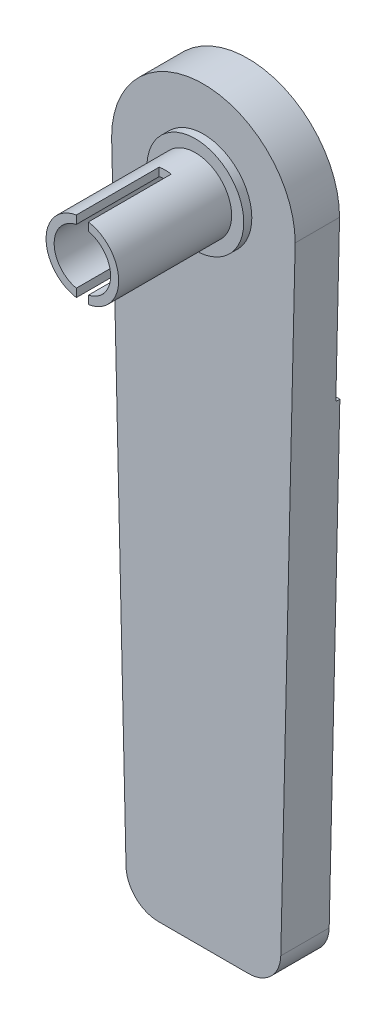
from build123d import *

# Parameters (mm, degrees)
EXTRUDE_1_DEPTH     = 6
FILLET_1_R          = 4
SKETCH_2_R          = 4.5
EXTRUDE_2_DEPTH     = 15
SKETCH_4_R          = 6
EXTRUDE_3_DEPTH     = 1
SKETCH_5_R          = 3.5
CUT_EXTRUDE_1_DEPTH = 15
SKETCH_6_W          = 1.5
SKETCH_6_H          = 10.26625424
CUT_EXTRUDE_2_DEPTH = 16.875
CUT_EXTRUDE_3_DEPTH = 0.5


with BuildPart() as part:
    # 草圖1 → 填料-伸長1 (new body)
    with BuildSketch(Plane.XY):
        with BuildLine():
            Line((-11.362913376, -0.524237167), (-9.5, -81.325))
            Line((-9.5, -81.325), (9.5, -81.325))
            Line((9.5, -81.325), (11.362913376, -0.524237167))
            Line((11.362913376, -0.524237167), (11.375, 0))
            ThreePointArc((11.375, 0), (0, 11.375), (-11.375, 0))
            Line((-11.375, 0), (-11.362913376, -0.524237167))
        make_face()
    extrude(amount=EXTRUDE_1_DEPTH)

    # 圓角1
    fillet_1_edges = [part.edges().sort_by_distance(p)[0] for p in [
        (9.5, -81.325, 3),
        (-9.5, -81.325, 3),
    ]]
    fillet(fillet_1_edges, radius=FILLET_1_R)

    # 草圖2 → 填料-伸長2 (add)
    with BuildSketch(Plane.XY.offset(6)):
        Circle(SKETCH_2_R)
    extrude(amount=EXTRUDE_2_DEPTH)

    # 草圖4 → 填料-伸長3 (add)
    with BuildSketch(Plane.XY.offset(6)):
        Circle(SKETCH_4_R)
    extrude(amount=EXTRUDE_3_DEPTH)

    # 草圖5 → 除料-伸長1 (cut)
    with BuildSketch(Plane.XY.offset(21)):
        Circle(SKETCH_5_R)
    extrude(amount=-CUT_EXTRUDE_1_DEPTH, mode=Mode.SUBTRACT)

    # 草圖6 → 除料-伸長2 (cut, through all)
    with BuildSketch(Plane(origin=(0, -4.5, 0), x_dir=(-1, 0, 0), z_dir=(0, -1, 0))):
        with Locations((0, -15.86687288)):
            Rectangle(SKETCH_6_W, SKETCH_6_H)
    extrude(amount=-CUT_EXTRUDE_2_DEPTH, mode=Mode.SUBTRACT)

    # 草圖7 → 除料-伸長3 (cut)
    with BuildSketch(Plane(origin=(0, 0, 0), x_dir=(-1, 0, 0), z_dir=(0, 0, -1))):
        with BuildLine():
            Line((-10.913887181, -20), (10.913887181, -20))
            Line((10.913887181, -20), (11.375, 0))
            ThreePointArc((11.375, 0), (0, 11.375), (-11.375, 0))
            Line((-11.375, 0), (-10.913887181, -20))
        make_face()
    extrude(amount=-CUT_EXTRUDE_3_DEPTH, mode=Mode.SUBTRACT)


solid = part.part
